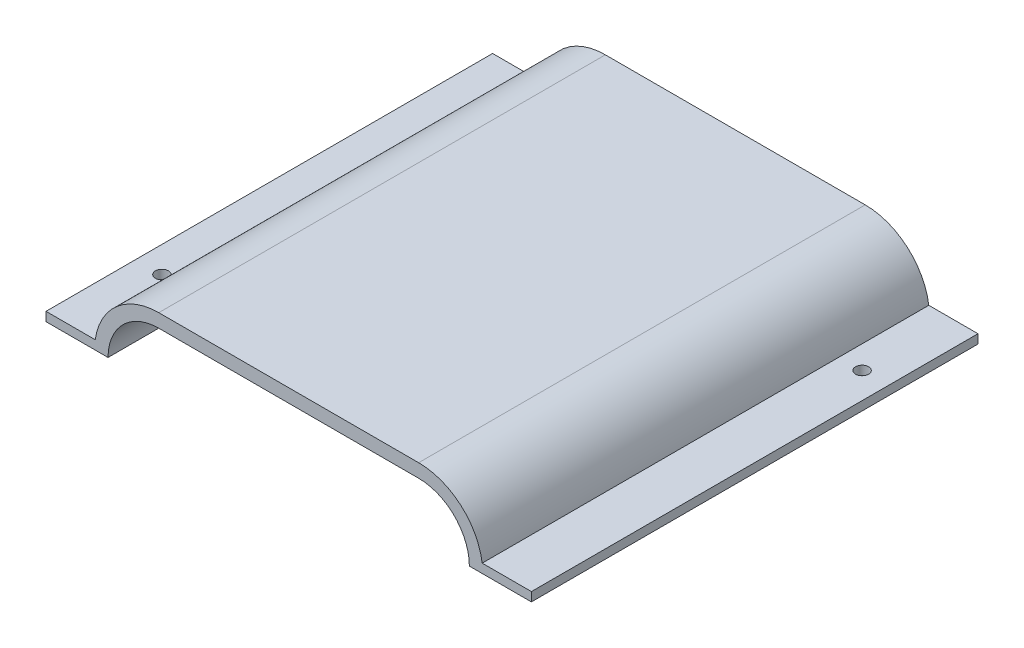
from build123d import *

# Parameters (mm, degrees)
BOSS_EXTRUDE1_DEPTH = 99.5
SKETCH3_R           = 1.45
CUT_EXTRUDE1_DEPTH  = 2


with BuildPart() as part:
    # Sketch1 → Boss-Extrude1 (new body)
    with BuildSketch(Plane.XY):
        with BuildLine():
            Line((-43.109449142, 21.05), (-40.071600604, 21.05))
            ThreePointArc((-40.071600604, 21.05), (-36.198793003, 27.718621574), (-28.95, 30.35))
            Line((-28.95, 30.35), (28.95, 30.35))
            ThreePointArc((28.95, 30.35), (36.198793003, 27.718621574), (40.071600604, 21.05))
            Line((40.071600604, 21.05), (43.109449142, 21.05))
            ThreePointArc((43.109449142, 21.05), (38.327899552, 29.845600956), (28.95, 33.35))
            Line((28.95, 33.35), (-28.95, 33.35))
            ThreePointArc((-28.95, 33.35), (-38.327899552, 29.845600956), (-43.109449142, 21.05))
        make_face()
        with BuildLine():
            Line((-43.25, 19.05), (-40.25, 19.05))
            ThreePointArc((-40.25, 19.05), (-40.205311787, 20.053970411), (-40.071600604, 21.05))
            Line((-40.071600604, 21.05), (-43.109449142, 21.05))
            ThreePointArc((-43.109449142, 21.05), (-43.214819009, 20.052466277), (-43.25, 19.05))
        make_face()
        with BuildLine():
            Line((-50.25, 19.05), (-43.25, 19.05))
            ThreePointArc((-43.25, 19.05), (-43.214819009, 20.052466277), (-43.109449142, 21.05))
            Line((-43.109449142, 21.05), (-54.071600604, 21.05))
            Line((-54.071600604, 21.05), (-54.071600604, 19.05))
            Line((-54.071600604, 19.05), (-50.25, 19.05))
        make_face()
        with BuildLine():
            ThreePointArc((40.071600604, 21.05), (40.205311787, 20.053970411), (40.25, 19.05))
            Line((40.25, 19.05), (43.25, 19.05))
            ThreePointArc((43.25, 19.05), (43.214819009, 20.052466277), (43.109449142, 21.05))
            Line((43.109449142, 21.05), (40.071600604, 21.05))
        make_face()
        with BuildLine():
            ThreePointArc((43.109449142, 21.05), (43.214819009, 20.052466277), (43.25, 19.05))
            Line((43.25, 19.05), (50.25, 19.05))
            Line((50.25, 19.05), (54.071600604, 19.05))
            Line((54.071600604, 19.05), (54.071600604, 21.05))
            Line((54.071600604, 21.05), (43.109449142, 21.05))
        make_face()
    extrude(amount=BOSS_EXTRUDE1_DEPTH)

    # Sketch3 → Cut-Extrude1 (cut)
    with BuildSketch(Plane.XZ.offset(-19.05)):
        with Locations((-48.25, 79.5)):
            Circle(SKETCH3_R)
        with Locations((48.25, 20)):
            Circle(SKETCH3_R)
    extrude(amount=-CUT_EXTRUDE1_DEPTH, mode=Mode.SUBTRACT)


solid = part.part
